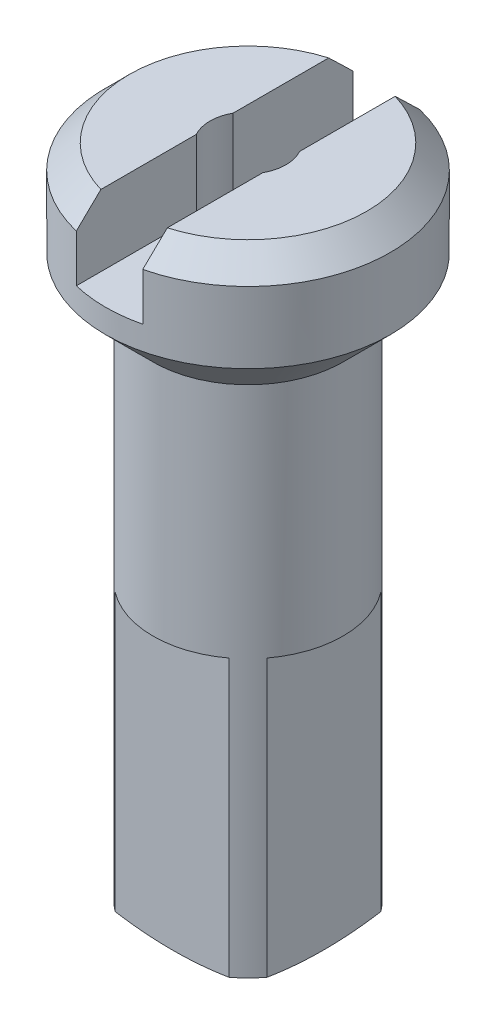
from build123d import *

# Parameters (mm, degrees)
CHANFREIN1_SIZE         = 0.5
ESQUISSE3_W             = 1.4
ESQUISSE3_H             = 6
ENL_V_MAT_EXTRU_1_DEPTH = 1.5
ENL_V_START             = -8
ESQUISSE4_OUTSIDE_W     = 11.274
ESQUISSE4_OUTSIDE_H     = 11.274
ESQUISSE4_OUTSIDE_W_2   = 3.2
ESQUISSE4_OUTSIDE_H_2   = 3.2
ENL_V_MAT_EXTRU_2_DEPTH = 7


with BuildPart() as part:
    # Esquisse2 → Révolution1 (revolve)
    with BuildSketch(Plane.XY, mode=Mode.PRIVATE) as r_volution1_sk:
        with BuildLine():
            Line((-0.8, 0), (-3, 0))
            Line((-3, 0), (-3, -2))
            Line((-3, -2), (-2, -3))
            Line((-2, -3), (-2, -13.82503854))
            ThreePointArc((-2, -13.82503854), (-1.60238974, -13.923446201), (-1.2, -14))
            Line((-1.2, -14), (-1.2, -8))
            Line((-1.2, -8), (-0.8, -8))
            Line((-0.8, -8), (-0.8, 0))
        make_face()
    revolve(r_volution1_sk.sketch.rotate(Axis((0, -17.325308642, 0), (0, 1, 0)), 270), axis=Axis((0, -17.325308642, 0), (0, 1, 0)))  # turned: the seam where the file's is

    # Chanfrein1
    chanfrein1_edges = [part.edges().sort_by_distance(p)[0] for p in [
        (0, 0, 3),
    ]]
    chamfer(chanfrein1_edges, length=CHANFREIN1_SIZE)

    # Esquisse3 → Enlèv. mat.-Extru.1 (cut)
    with BuildSketch(Plane(origin=(0, 0, 0), x_dir=(-1, 0, 0), z_dir=(0, 1, 0))):
        Rectangle(ESQUISSE3_W, ESQUISSE3_H)
    extrude(amount=-ENL_V_MAT_EXTRU_1_DEPTH, mode=Mode.SUBTRACT)

    # Esquisse4 outside → Enlèv. mat.-Extru.2 (cut, through all)
    with BuildSketch(Plane(origin=(0, 0, 0), x_dir=(-1, 0, 0), z_dir=(0, 1, 0)).offset(ENL_V_START)):
        Rectangle(ESQUISSE4_OUTSIDE_W, ESQUISSE4_OUTSIDE_H)
        Rectangle(ESQUISSE4_OUTSIDE_W_2, ESQUISSE4_OUTSIDE_H_2, mode=Mode.SUBTRACT)
    extrude(amount=-ENL_V_MAT_EXTRU_2_DEPTH, mode=Mode.SUBTRACT)


solid = part.part
